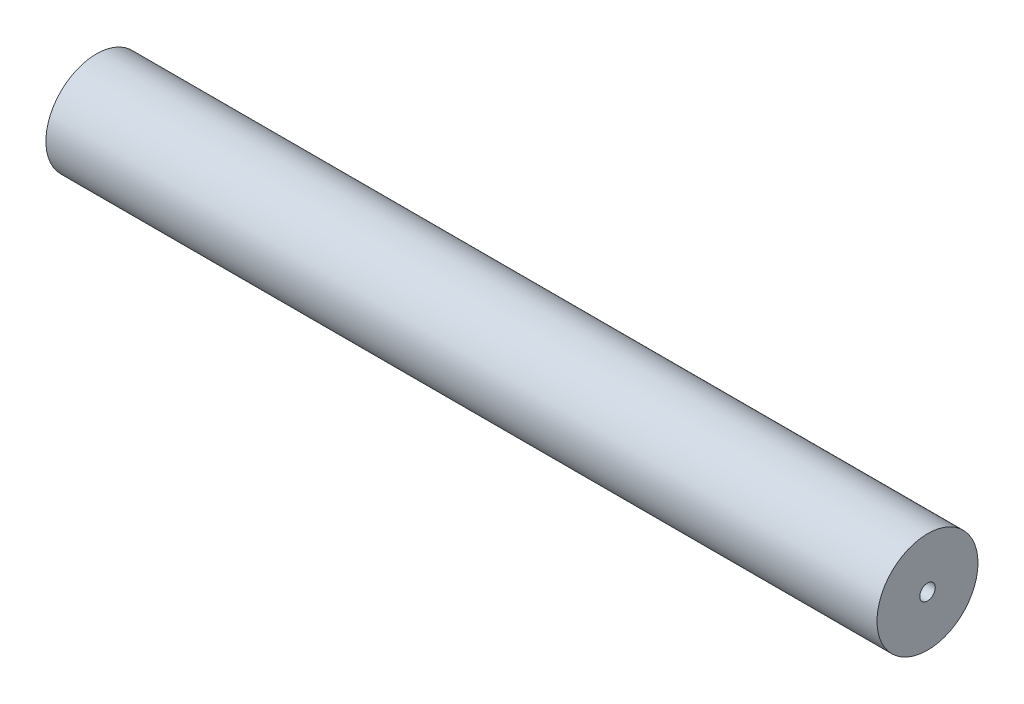
from build123d import *


with BuildPart() as part:
    # Sketch1 → Revolve1 (revolve)
    with BuildSketch(Plane.XY):
        Polygon((11, 0.5), (11, 3.25), (-42.5, 3.25), (-42.5, 2.25), (10, 2.25), (10, 0.5), align=None)
    revolve(axis=Axis((13.5, 0, 0), (-1, 0, 0)))


solid = part.part
